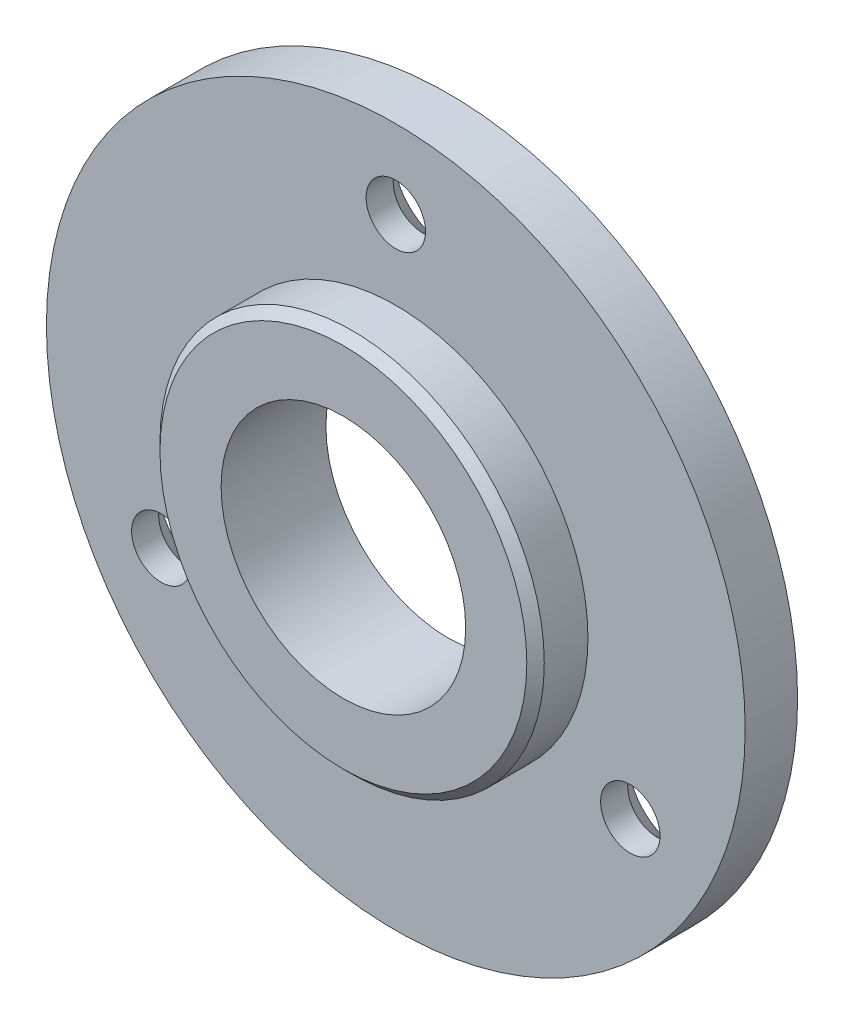
from build123d import *

# Parameters (mm, degrees)
ESQUISSE1_R                                    = 20
BOSS_EXTRU_1_DEPTH                             = 3
ESQUISSE2_R                                    = 11
BOSS_EXTRU_2_DEPTH                             = 3
CHANFREIN1_SIZE                                = 0.5
ESQUISSE3_R                                    = 7
ENL_V_MAT_EXTRU_1_DEPTH                        = 7
FRAISAGE_POUR_VIS_T_TE_FRAIS_E_M32_D           = 3.4
FRAISAGE_POUR_VIS_T_TE_FRAIS_E_M32_CSINK_D     = 6.3
FRAISAGE_POUR_VIS_T_TE_FRAIS_E_M32_CSINK_ANGLE = 90
R_P_TITION_CIRCULAIRE1_COUNT                   = 3


with BuildPart() as part:
    # Esquisse1 → Boss.-Extru.1 (new body)
    with BuildSketch(Plane.XY):
        Circle(ESQUISSE1_R)
    extrude(amount=BOSS_EXTRU_1_DEPTH)

    # Esquisse2 → Boss.-Extru.2 (add)
    with BuildSketch(Plane.XY.offset(3)):
        Circle(ESQUISSE2_R)
    extrude(amount=BOSS_EXTRU_2_DEPTH)

    # Chanfrein1
    chanfrein1_edges = [part.edges().sort_by_distance(p)[0] for p in [
        (-11, 0, 6),
    ]]
    chamfer(chanfrein1_edges, length=CHANFREIN1_SIZE)

    # Esquisse3 → Enlèv. mat.-Extru.1 (cut, through all)
    with BuildSketch(Plane(origin=(0, 0, 0), x_dir=(-1, 0, 0), z_dir=(0, 0, -1))):
        Circle(ESQUISSE3_R)
    extrude(amount=-ENL_V_MAT_EXTRU_1_DEPTH, mode=Mode.SUBTRACT)

    # Fraisage pour vis à tête fraisée M32 (through all)
    with Locations(Plane(origin=(0, 0, 0), x_dir=(-1, 0, 0), z_dir=(0, 0, -1))):
        with Locations((0, 15.5)):
            fraisage_pour_vis_t_te_frais_e_m32 = CounterSinkHole(FRAISAGE_POUR_VIS_T_TE_FRAIS_E_M32_D / 2, FRAISAGE_POUR_VIS_T_TE_FRAIS_E_M32_CSINK_D / 2, counter_sink_angle=FRAISAGE_POUR_VIS_T_TE_FRAIS_E_M32_CSINK_ANGLE)

    # Répétition circulaire1: Fraisage pour vis à tête fraisée M32 ×3 about axis
    r_p_tition_circulaire1_axis = Axis((0, 0, 0), (0, 0, 1))
    for i in range(1, R_P_TITION_CIRCULAIRE1_COUNT):
        add(fraisage_pour_vis_t_te_frais_e_m32.rotate(r_p_tition_circulaire1_axis, i * 360 / R_P_TITION_CIRCULAIRE1_COUNT), mode=Mode.SUBTRACT)


solid = part.part
